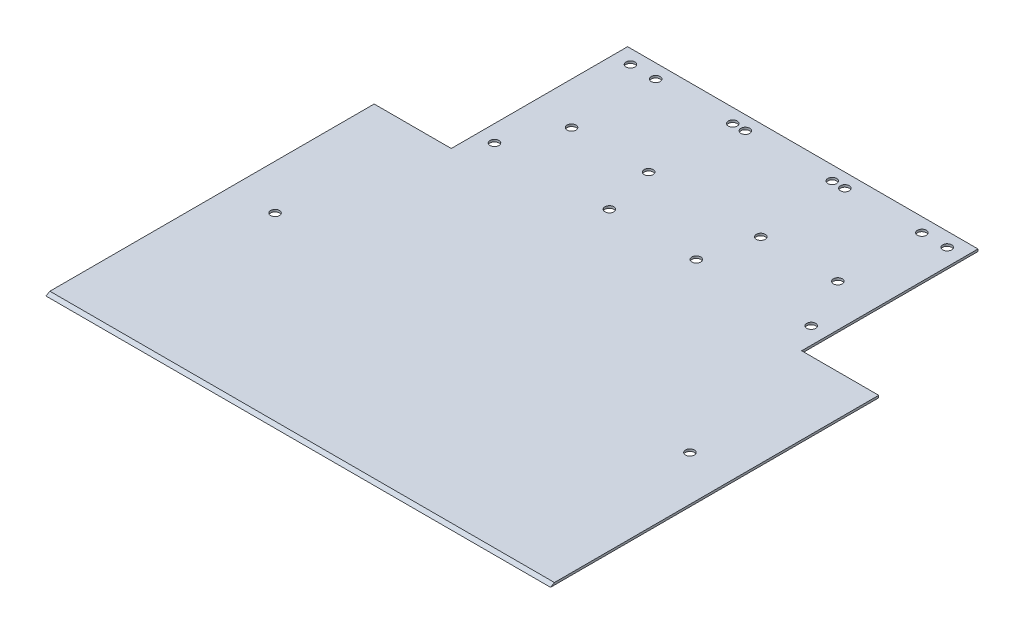
from build123d import *

# Parameters (mm, degrees)
SALIENTE_EXTRUIR1_DEPTH = 0.8
CORTAR_EXTRUIR1_REACH   = 182
CROQUIS3_R              = 1.585
CORTAR_EXTRUIR2_DEPTH   = 0.8
CORTAR_EXTRUIR3_REACH   = 2.8
CROQUIS4_R              = 1.585
CORTAR_EXTRUIR4_REACH   = 2.8
CROQUIS6_R              = 1.585
CROQUIS7_R              = 1.585
CORTAR_EXTRUIR5_DEPTH   = 0.8


with BuildPart() as part:
    # Croquis1 → Saliente-Extruir1 (new body)
    with BuildSketch(Plane(origin=(0, 0, 0), x_dir=(1, 0, 0), z_dir=(0, 1, 0))):
        Polygon((-62.5, 90), (-62.5, 27.08), (-90, 27.08), (-90, -90), (90, -90), (90, 27.08), (62.5, 27.08), (62.5, 90), align=None)
    extrude(amount=SALIENTE_EXTRUIR1_DEPTH)

    # Croquis2 → Cortar-Extruir1 (cut, up to next)
    with BuildSketch(Plane.ZY.offset(90), mode=Mode.PRIVATE) as cortar_extruir1_sk1:
        Polygon((90, 0), (88.614359354, 0.8), (90, 0.8), align=None)
    cortar_extruir1_tool1 = extrude(cortar_extruir1_sk1.sketch, amount=-CORTAR_EXTRUIR1_REACH, mode=Mode.PRIVATE) & part.part
    add(cortar_extruir1_tool1.solids().sort_by_distance((-90, 0.533333, 89.53812))[0], mode=Mode.SUBTRACT)

    # Croquis3 → Cortar-Extruir2 (cut)
    with BuildSketch(Plane(origin=(0, 0.8, 0), x_dir=(1, 0, 0), z_dir=(0, 1, 0))):
        with Locations((74, -24.279339937)):
            Circle(CROQUIS3_R)
    cortar_extruir2 = extrude(amount=-CORTAR_EXTRUIR2_DEPTH, mode=Mode.SUBTRACT)

    # Simetría1: Cortar-Extruir2 across plane
    add(cortar_extruir2.mirror(Plane(origin=(0, 0, 0), x_dir=(0, 0, 1), z_dir=(1, 0, 0))), mode=Mode.SUBTRACT)

    # Croquis4 → Cortar-Extruir3 (cut, up to next)
    with BuildSketch(Plane(origin=(0, 0.8, 0), x_dir=(1, 0, 0), z_dir=(0, 1, 0)), mode=Mode.PRIVATE) as cortar_extruir3_sk1:
        with Locations((-56.5, 36.505640646)):
            Circle(CROQUIS4_R)
    cortar_extruir3_tool1 = extrude(cortar_extruir3_sk1.sketch, amount=-CORTAR_EXTRUIR3_REACH, mode=Mode.PRIVATE) & part.part
    add(cortar_extruir3_tool1.solids().sort_by_distance((-56.5, 0.8, -36.505641))[0], mode=Mode.SUBTRACT)
    # Croquis4 → Cortar-Extruir3 (cut, up to next)
    with BuildSketch(Plane(origin=(0, 0.8, 0), x_dir=(1, 0, 0), z_dir=(0, 1, 0)), mode=Mode.PRIVATE) as cortar_extruir3_sk2:
        with Locations((-15.5, 36.505640646)):
            Circle(CROQUIS4_R)
    cortar_extruir3_tool2 = extrude(cortar_extruir3_sk2.sketch, amount=-CORTAR_EXTRUIR3_REACH, mode=Mode.PRIVATE) & part.part
    add(cortar_extruir3_tool2.solids().sort_by_distance((-15.5, 0.8, -36.505641))[0], mode=Mode.SUBTRACT)
    # Croquis4 → Cortar-Extruir3 (cut, up to next)
    with BuildSketch(Plane(origin=(0, 0.8, 0), x_dir=(1, 0, 0), z_dir=(0, 1, 0)), mode=Mode.PRIVATE) as cortar_extruir3_sk3:
        with Locations((-15.5, 85.005640646)):
            Circle(CROQUIS4_R)
    cortar_extruir3_tool3 = extrude(cortar_extruir3_sk3.sketch, amount=-CORTAR_EXTRUIR3_REACH, mode=Mode.PRIVATE) & part.part
    add(cortar_extruir3_tool3.solids().sort_by_distance((-15.5, 0.8, -85.005641))[0], mode=Mode.SUBTRACT)
    # Croquis4 → Cortar-Extruir3 (cut, up to next)
    with BuildSketch(Plane(origin=(0, 0.8, 0), x_dir=(1, 0, 0), z_dir=(0, 1, 0)), mode=Mode.PRIVATE) as cortar_extruir3_sk4:
        with Locations((-56.5, 85.005640646)):
            Circle(CROQUIS4_R)
    cortar_extruir3_tool4 = extrude(cortar_extruir3_sk4.sketch, amount=-CORTAR_EXTRUIR3_REACH, mode=Mode.PRIVATE) & part.part
    add(cortar_extruir3_tool4.solids().sort_by_distance((-56.5, 0.8, -85.005641))[0], mode=Mode.SUBTRACT)

    # Croquis6 → Cortar-Extruir4 (cut, up to next)
    with BuildSketch(Plane(origin=(0, 0.8, 0), x_dir=(1, 0, 0), z_dir=(0, 1, 0)), mode=Mode.PRIVATE) as cortar_extruir4_sk1:
        with Locations((56.5, 85.005640646)):
            Circle(CROQUIS6_R)
    cortar_extruir4_tool1 = extrude(cortar_extruir4_sk1.sketch, amount=-CORTAR_EXTRUIR4_REACH, mode=Mode.PRIVATE) & part.part
    add(cortar_extruir4_tool1.solids().sort_by_distance((56.5, 0.8, -85.005641))[0], mode=Mode.SUBTRACT)
    # Croquis6 → Cortar-Extruir4 (cut, up to next)
    with BuildSketch(Plane(origin=(0, 0.8, 0), x_dir=(1, 0, 0), z_dir=(0, 1, 0)), mode=Mode.PRIVATE) as cortar_extruir4_sk2:
        with Locations((15.5, 85.005640646)):
            Circle(CROQUIS6_R)
    cortar_extruir4_tool2 = extrude(cortar_extruir4_sk2.sketch, amount=-CORTAR_EXTRUIR4_REACH, mode=Mode.PRIVATE) & part.part
    add(cortar_extruir4_tool2.solids().sort_by_distance((15.5, 0.8, -85.005641))[0], mode=Mode.SUBTRACT)
    # Croquis6 → Cortar-Extruir4 (cut, up to next)
    with BuildSketch(Plane(origin=(0, 0.8, 0), x_dir=(1, 0, 0), z_dir=(0, 1, 0)), mode=Mode.PRIVATE) as cortar_extruir4_sk3:
        with Locations((15.5, 36.505640646)):
            Circle(CROQUIS6_R)
    cortar_extruir4_tool3 = extrude(cortar_extruir4_sk3.sketch, amount=-CORTAR_EXTRUIR4_REACH, mode=Mode.PRIVATE) & part.part
    add(cortar_extruir4_tool3.solids().sort_by_distance((15.5, 0.8, -36.505641))[0], mode=Mode.SUBTRACT)
    # Croquis6 → Cortar-Extruir4 (cut, up to next)
    with BuildSketch(Plane(origin=(0, 0.8, 0), x_dir=(1, 0, 0), z_dir=(0, 1, 0)), mode=Mode.PRIVATE) as cortar_extruir4_sk4:
        with Locations((56.5, 36.505640646)):
            Circle(CROQUIS6_R)
    cortar_extruir4_tool4 = extrude(cortar_extruir4_sk4.sketch, amount=-CORTAR_EXTRUIR4_REACH, mode=Mode.PRIVATE) & part.part
    add(cortar_extruir4_tool4.solids().sort_by_distance((56.5, 0.8, -36.505641))[0], mode=Mode.SUBTRACT)

    # Croquis7 → Cortar-Extruir5 (cut)
    with BuildSketch(Plane(origin=(0, 0.8, 0), x_dir=(1, 0, 0), z_dir=(0, 1, 0))):
        with Locations((-20, 85.005640646)):
            Circle(CROQUIS7_R)
        with Locations((-47.5, 85.005640646)):
            Circle(CROQUIS7_R)
        with Locations((-47.5, 55.005640646)):
            Circle(CROQUIS7_R)
        with Locations((-20, 55.005640646)):
            Circle(CROQUIS7_R)
    cortar_extruir5 = extrude(amount=-CORTAR_EXTRUIR5_DEPTH, mode=Mode.SUBTRACT)

    # Simetría2: Cortar-Extruir5 across plane
    add(cortar_extruir5.mirror(Plane(origin=(0, 0, 0), x_dir=(0, 0, 1), z_dir=(1, 0, 0))), mode=Mode.SUBTRACT)


solid = part.part
